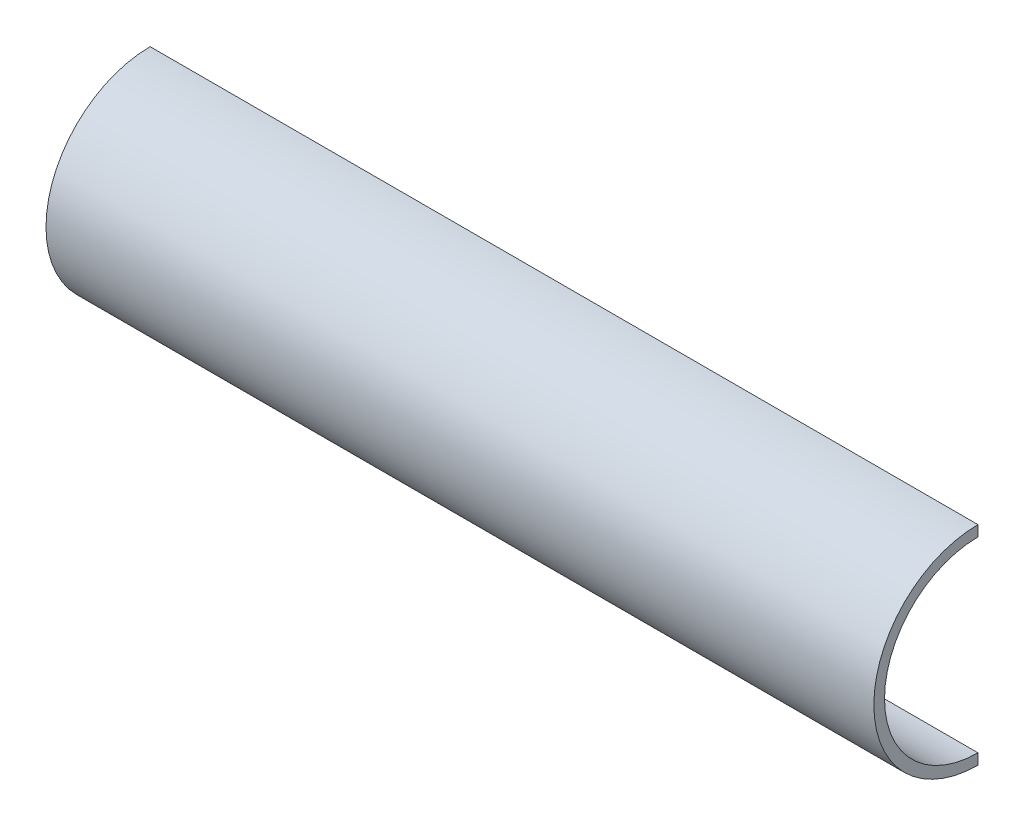
from build123d import *

# Parameters (mm, degrees)
BOSS_EXTRUDE1_DEPTH = 310


with BuildPart() as part:
    # Sketch1 → Boss-Extrude1 (new body)
    with BuildSketch(Plane(origin=(0, 0, 0), x_dir=(0, 0, -1), z_dir=(1, 0, 0))):
        with BuildLine():
            ThreePointArc((0, -35), (-35, 0), (0, 35))
            Line((0, 35), (0, 39))
            ThreePointArc((0, 39), (-39, 0), (0, -39))
            Line((0, -39), (0, -35))
        make_face()
    extrude(amount=BOSS_EXTRUDE1_DEPTH)


solid = part.part
